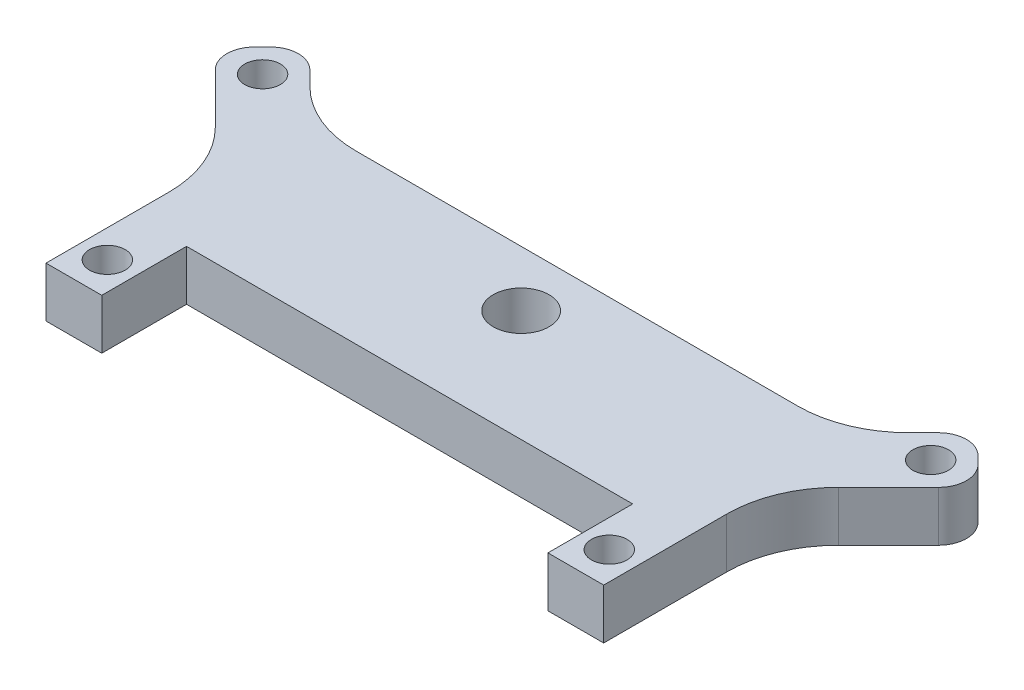
from build123d import *

# Parameters (mm, degrees)
SKETCH1_R           = 1.6
SKETCH1_R_2         = 2.5
BOSS_EXTRUDE1_DEPTH = 4.5
FILLET1_R           = 10
FILLET2_R           = 2.5


with BuildPart() as part:
    # Sketch1 → Boss-Extrude1 (new body)
    with BuildSketch(Plane(origin=(0, 0, 0), x_dir=(1, 0, 0), z_dir=(0, 1, 0))):
        Polygon((-20, 0), (20, 0), (20, -7.6), (25, -7.6), (25, 7.575378798), (34.192388155, 16.767766953), (29.949747468, 21.01040764), (23.939339828, 15), (-23.939339828, 15), (-29.949747468, 21.01040764), (-34.192388155, 16.767766953), (-25, 7.575378798), (-25, -7.6), (-20, -7.6), align=None)
        with Locations((-22.5, -4.6)):
            Circle(SKETCH1_R, mode=Mode.SUBTRACT)
        with Locations((22.5, -4.6)):
            Circle(SKETCH1_R, mode=Mode.SUBTRACT)
        with Locations((-29.949747468, 16.767766953)):
            Circle(SKETCH1_R, mode=Mode.SUBTRACT)
        with Locations((29.949747468, 16.767766953)):
            Circle(SKETCH1_R, mode=Mode.SUBTRACT)
        with Locations((0, 10)):
            Circle(SKETCH1_R_2, mode=Mode.SUBTRACT)
    extrude(amount=BOSS_EXTRUDE1_DEPTH)

    # Fillet1
    fillet1_edges = [part.edges().sort_by_distance(p)[0] for p in [
        (-25, 2.25, -7.575378798),
        (-23.939339828, 2.25, -15),
        (23.939339828, 2.25, -15),
        (25, 2.25, -7.575378798),
    ]]
    fillet(fillet1_edges, radius=FILLET1_R)

    # Fillet2
    fillet2_edges = [part.edges().sort_by_distance(p)[0] for p in [
        (-34.192388155, 2.25, -16.767766953),
        (-29.949747468, 2.25, -21.01040764),
        (29.949747468, 2.25, -21.01040764),
        (34.192388155, 2.25, -16.767766953),
    ]]
    fillet(fillet2_edges, radius=FILLET2_R)


solid = part.part
